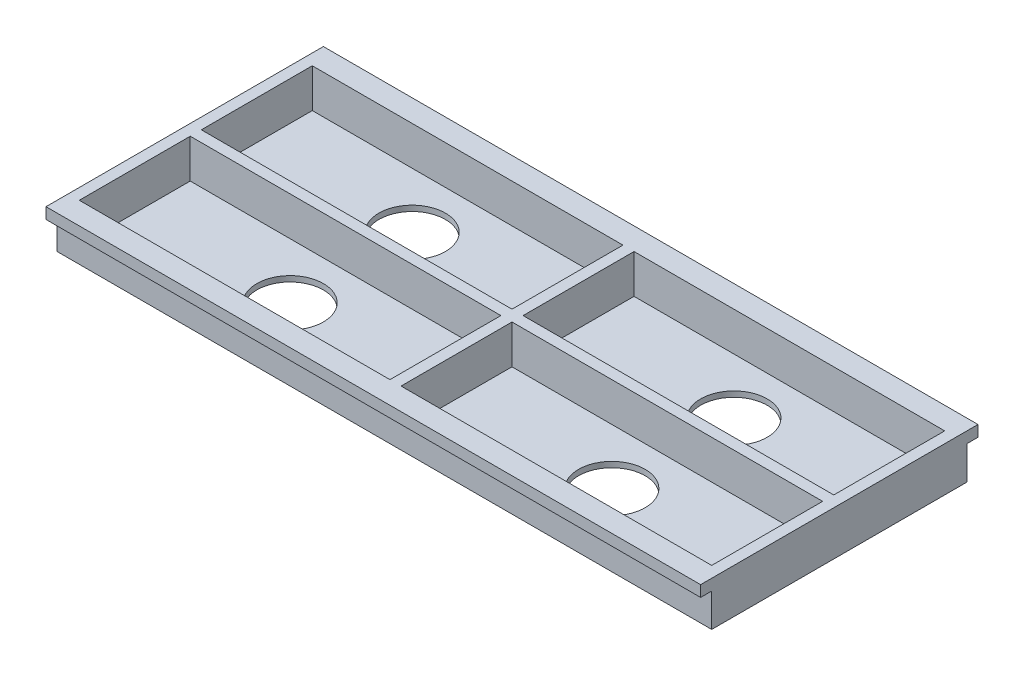
from build123d import *

# Parameters (mm, degrees)
SKETCH1_W           = 295
SKETCH1_H           = 125
BOSS_EXTRUDE3_DEPTH = 5
SKETCH2_W           = 295
SKETCH2_H           = 115
BOSS_EXTRUDE4_DEPTH = 20
SKETCH4_W           = 140
SKETCH4_H           = 50
CUT_EXTRUDE1_DEPTH  = 17.5
SKETCH4_3_W         = 140
SKETCH4_3_H         = 50
CUT_EXTRUDE2_DEPTH  = 17.5
SKETCH7_R           = 15
CUT_EXTRUDE3_DEPTH  = 31.5


with BuildPart() as part:
    # Sketch1 → Boss-Extrude3 (new body)
    with BuildSketch(Plane(origin=(0, 0, 0), x_dir=(1, 0, 0), z_dir=(0, 1, 0))):
        with Locations((24.344660194, 23.262829884)):
            Rectangle(SKETCH1_W, SKETCH1_H)
    extrude(amount=-BOSS_EXTRUDE3_DEPTH)

    # Sketch2 → Boss-Extrude4 (add)
    with BuildSketch(Plane(origin=(0, 0, 0), x_dir=(1, 0, 0), z_dir=(0, 1, 0))):
        with Locations((24.344660194, 23.262829884)):
            Rectangle(SKETCH2_W, SKETCH2_H)
    extrude(amount=-BOSS_EXTRUDE4_DEPTH)

    # Sketch4 → Cut-Extrude1 (cut)
    with BuildSketch(Plane(origin=(0, 0, 0), x_dir=(1, 0, 0), z_dir=(0, 1, 0))):
        with Locations((-48.155339806, 50.762829884)):
            Rectangle(SKETCH4_W, SKETCH4_H)
    extrude(amount=-CUT_EXTRUDE1_DEPTH, mode=Mode.SUBTRACT)

    # Sketch4_3 → Cut-Extrude2 (cut)
    with BuildSketch(Plane(origin=(0, 0, 0), x_dir=(1, 0, 0), z_dir=(0, 1, 0))):
        with Locations((-48.155339806, 50.762829884)):
            Rectangle(SKETCH4_3_W, SKETCH4_3_H)
        with Locations((96.844660194, 50.762829884)):
            Rectangle(SKETCH4_3_W, SKETCH4_3_H)
        with Locations((96.844660194, -4.237170116)):
            Rectangle(SKETCH4_3_W, SKETCH4_3_H)
        with Locations((-48.155339806, -4.237170116)):
            Rectangle(SKETCH4_3_W, SKETCH4_3_H)
    extrude(amount=-CUT_EXTRUDE2_DEPTH, mode=Mode.SUBTRACT)

    # Sketch7 → Cut-Extrude3 (cut)
    with BuildSketch(Plane(origin=(0, -17.5, 0), x_dir=(1, 0, 0), z_dir=(0, 1, 0))):
        with Locations((-48.155339806, -4.237170116)):
            Circle(SKETCH7_R)
        with Locations((96.844660194, -4.237170116)):
            Circle(SKETCH7_R)
        with Locations((96.844660194, 50.762829884)):
            Circle(SKETCH7_R)
        with Locations((-48.155339806, 50.762829884)):
            Circle(SKETCH7_R)
    extrude(amount=-CUT_EXTRUDE3_DEPTH, mode=Mode.SUBTRACT)


solid = part.part
